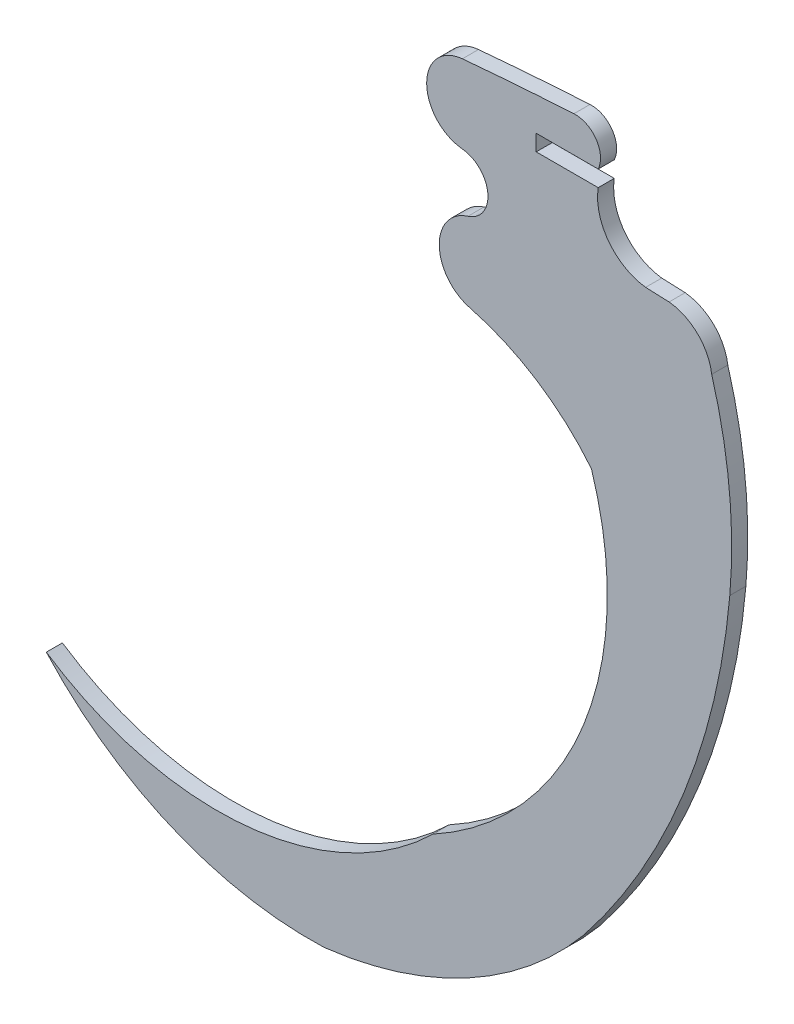
from build123d import *

# Parameters (mm, degrees)
BOSS_EXTRUDE1_DEPTH = 1.524


with BuildPart() as part:
    # Sketch1 → Boss-Extrude1 (new body)
    with BuildSketch(Plane.XY):
        with BuildLine():
            Line((8.098483712, 11.859727981), (5.877367718, 11.949858026))
            ThreePointArc((5.877367718, 11.949858026), (2.370350057, 13.962618774), (1.378838723, 17.882731524))
            Line((1.378838723, 17.882731524), (-4.494535751, 17.881911563))
            Line((-4.494535751, 17.881911563), (-4.494535751, 19.408886177))
            Line((-4.494535751, 19.408886177), (1.380889641, 19.408886177))
            ThreePointArc((1.380889641, 19.408886177), (1.19021021, 21.756216477), (-0.921759528, 22.798282696))
            ThreePointArc((-0.921759528, 22.798282696), (-6.208886665, 22.451672785), (-11.489936734, 22.022298875))
            ThreePointArc((-11.489936734, 22.022298875), (-14.876191758, 18.331465892), (-11.509843158, 14.622467604))
            ThreePointArc((-11.509843158, 14.622467604), (-9.080668933, 12.21547028), (-10.965433597, 9.362018739))
            ThreePointArc((-10.965433597, 9.362018739), (-13.682519769, 5.593287076), (-10.802877432, 1.947254215))
            ThreePointArc((-10.802877432, 1.947254215), (-4.434214721, -0.855352195), (0.739102642, -5.50844309))
            ThreePointArc((0.739102642, -5.50844309), (-0.02520916, -26.956652298), (-14.27594324, -43.004282308))
            ThreePointArc((-14.27594324, -43.004282308), (-31.998801932, -51.188810857), (-50.921597015, -46.391514323))
            ThreePointArc((-50.921597015, -46.391514323), (-38.979769068, -54.843194408), (-24.585605901, -57.4597222))
            ThreePointArc((-24.585605901, -57.4597222), (-11.010595968, -53.177928069), (0, -44.156762285))
            ThreePointArc((0, -44.156762285), (9.481977012, -27.77313527), (13.853593601, -9.35520676))
            ThreePointArc((13.853593601, -9.35520676), (13.803097482, -0.628370713), (12.139120175, 7.938507176))
            ThreePointArc((12.139120175, 7.938507176), (10.799936026, 10.60099471), (8.098483712, 11.859727981))
        make_face()
    extrude(amount=BOSS_EXTRUDE1_DEPTH)


solid = part.part
